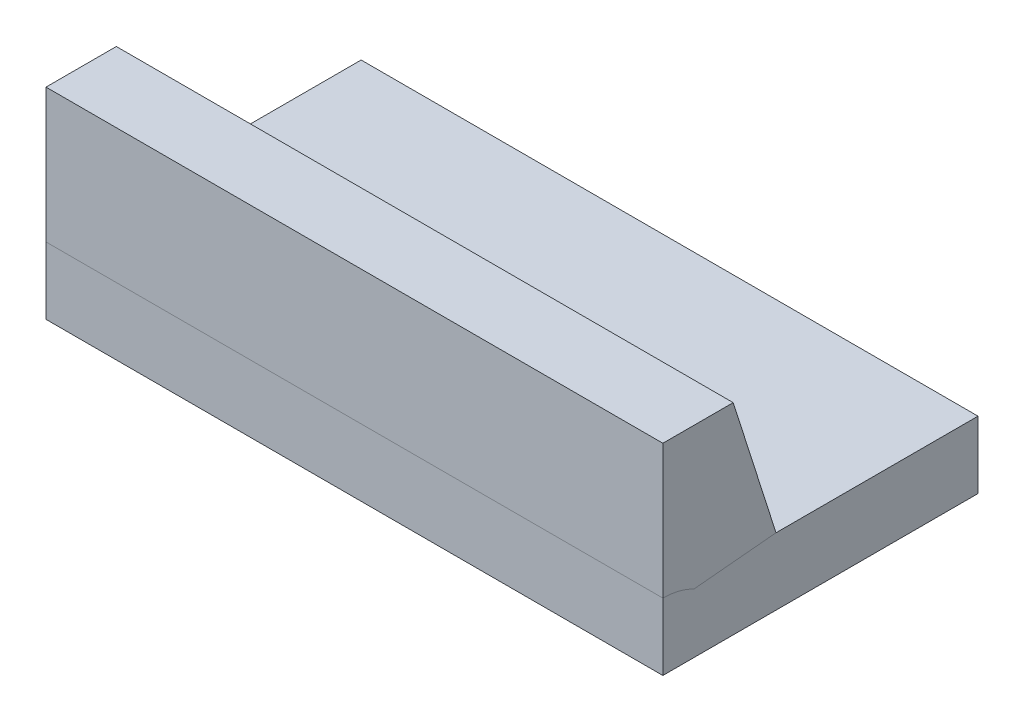
from build123d import *

# Parameters (mm, degrees)
SKETCH1_W               = 46
SKETCH1_H               = 23.5
BOSS_EXTRUDE1_DEPTH     = 5
SKETCH2_W               = 46
SKETCH2_H               = 10.437907818
BOSS_EXTRUDE2_DEPTH     = 10
SKETCH1_2_W             = 46
SKETCH1_2_H             = 23.5
BOSS_EXTRUDE3_DEPTH     = 5
SKETCH3_R               = 2
CUT_EXTRUDE1_DEPTH      = 10
CUT_EXTRUDE2_DEPTH      = 51.030535296
CUT_EXTRUDE2_DEPTH_BACK = 51.030535296
SKETCH4_R               = 5


with BuildPart() as part:
    # Sketch1 → Boss-Extrude1 (new body)
    with BuildSketch(Plane(origin=(0, 0, 0), x_dir=(1, 0, 0), z_dir=(0, 1, 0))):
        with Locations((-0.926380368, 0.98006135)):
            Rectangle(SKETCH1_W, SKETCH1_H)
    extrude(amount=BOSS_EXTRUDE1_DEPTH)


with BuildPart() as body_2:
    # Sketch2 → Boss-Extrude2 (new body)
    with BuildSketch(Plane(origin=(0, 5, 0), x_dir=(1, 0, 0), z_dir=(0, 1, 0))):
        with Locations((-0.926380368, -5.550984741)):
            Rectangle(SKETCH2_W, SKETCH2_H)
    extrude(amount=BOSS_EXTRUDE2_DEPTH)

    # Sketch1_2 → Boss-Extrude3 (add)
    with BuildSketch(Plane(origin=(0, 0, 0), x_dir=(1, 0, 0), z_dir=(0, 1, 0))):
        with Locations((-0.926380368, 0.98006135)):
            Rectangle(SKETCH1_2_W, SKETCH1_2_H)
    extrude(amount=BOSS_EXTRUDE3_DEPTH)

    # Sketch3 → Cut-Extrude1 (cut)
    with BuildSketch(Plane.XZ):
        with Locations((10.02395927, -4.311969164)):
            Circle(SKETCH3_R)
        with Locations((-11.975411965, -4.478063294)):
            Circle(SKETCH3_R)
    extrude(amount=-CUT_EXTRUDE1_DEPTH, mode=Mode.SUBTRACT)

    # Sketch4 → Cut-Extrude2 (cut, two sides: drawn at the far end of the back side and taken through both)
    with BuildSketch(Plane(origin=(22.073619632, 0, 0), x_dir=(0, 0, -1), z_dir=(1, 0, 0)).offset(-CUT_EXTRUDE2_DEPTH_BACK)):
        with Locations((-10.76993865, 0)):
            Circle(SKETCH4_R)
        Polygon((-0.332030832, 5), (-2.332030832, 5), (-5.525505132, 15), (-0.332030832, 15), align=None)
    extrude(amount=CUT_EXTRUDE2_DEPTH + CUT_EXTRUDE2_DEPTH_BACK, mode=Mode.SUBTRACT)


solid = Compound([part.part, body_2.part])
